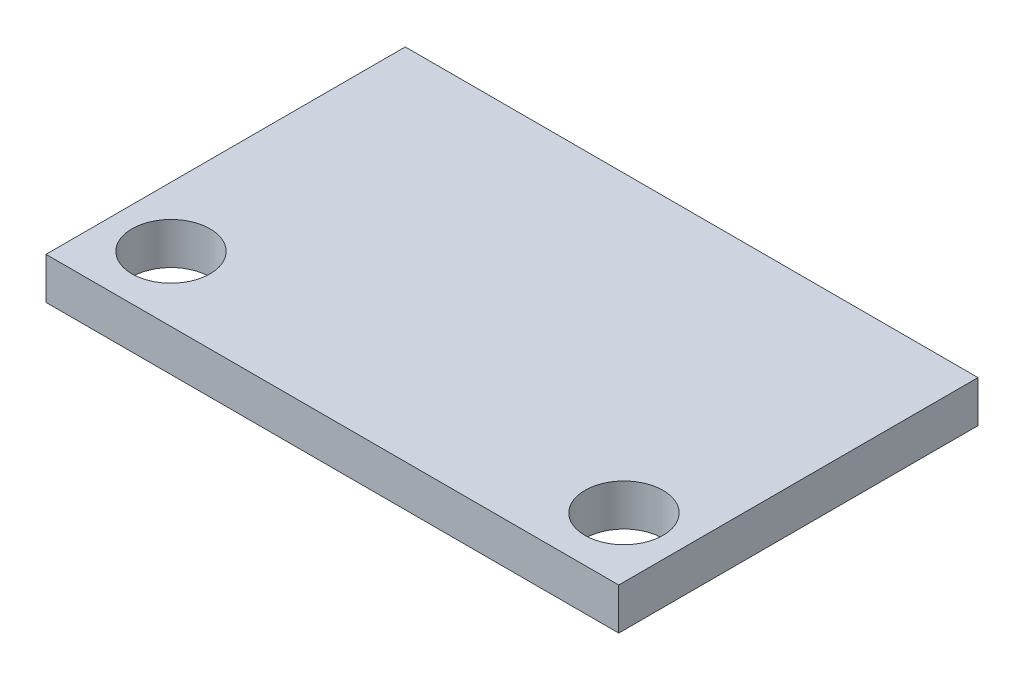
from build123d import *

# Parameters (mm, degrees)
SKETCH_1_W      = 22
SKETCH_1_H      = 13.8
SKETCH_1_R      = 1.5
EXTRUDE_1_DEPTH = 1.6


with BuildPart() as part:
    # 草图1 → 凸台-拉伸1 (new body)
    with BuildSketch(Plane(origin=(0, 0, 0), x_dir=(1, 0, 0), z_dir=(0, 1, 0))):
        Rectangle(SKETCH_1_W, SKETCH_1_H)
        with Locations((-8.7, -4.4)):
            Circle(SKETCH_1_R, mode=Mode.SUBTRACT)
        with Locations((8.7, -4.4)):
            Circle(SKETCH_1_R, mode=Mode.SUBTRACT)
    extrude(amount=EXTRUDE_1_DEPTH)


solid = part.part
